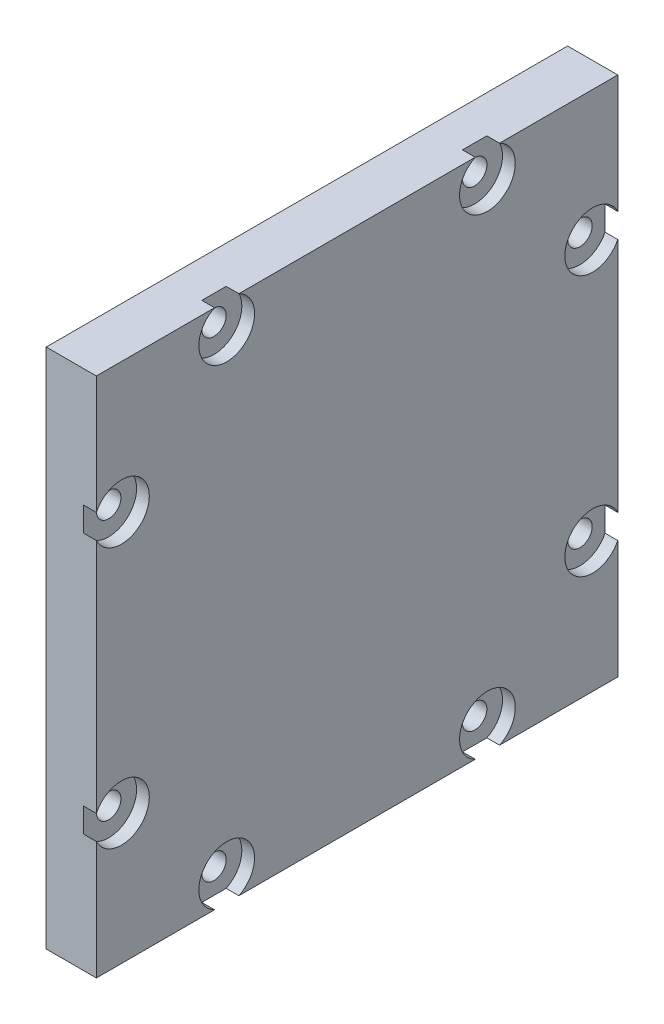
from build123d import *

# Parameters (mm, degrees)
SKETCH1_W                                           = 52
SKETCH1_H                                           = 52
BOSS_EXTRUDE1_DEPTH                                 = 5
CBORE_FOR_2_BINDING_HEAD_MACHINE_SCREW1_D           = 2.4384
CBORE_FOR_2_BINDING_HEAD_MACHINE_SCREW1_CBORE_D     = 5.55752
CBORE_FOR_2_BINDING_HEAD_MACHINE_SCREW1_CBORE_DEPTH = 1.27


with BuildPart() as part:
    # Sketch1 → Boss-Extrude1 (new body)
    with BuildSketch(Plane(origin=(0, 0, 0), x_dir=(0, 0, -1), z_dir=(1, 0, 0))):
        with Locations((26, 26)):
            Rectangle(SKETCH1_W, SKETCH1_H)
    extrude(amount=BOSS_EXTRUDE1_DEPTH)

    # CBORE for #2 Binding Head Machine Screw1 (through all)
    with Locations(Plane(origin=(5, 0, 0), x_dir=(0, 0, -1), z_dir=(1, 0, 0))):
        with Locations((13, 49.5), (39, 49.5), (49.5, 39), (49.5, 13), (39, 2.5), (13, 2.5), (2.5, 13), (2.5, 39)):
            CounterBoreHole(CBORE_FOR_2_BINDING_HEAD_MACHINE_SCREW1_D / 2, CBORE_FOR_2_BINDING_HEAD_MACHINE_SCREW1_CBORE_D / 2, CBORE_FOR_2_BINDING_HEAD_MACHINE_SCREW1_CBORE_DEPTH)


solid = part.part
